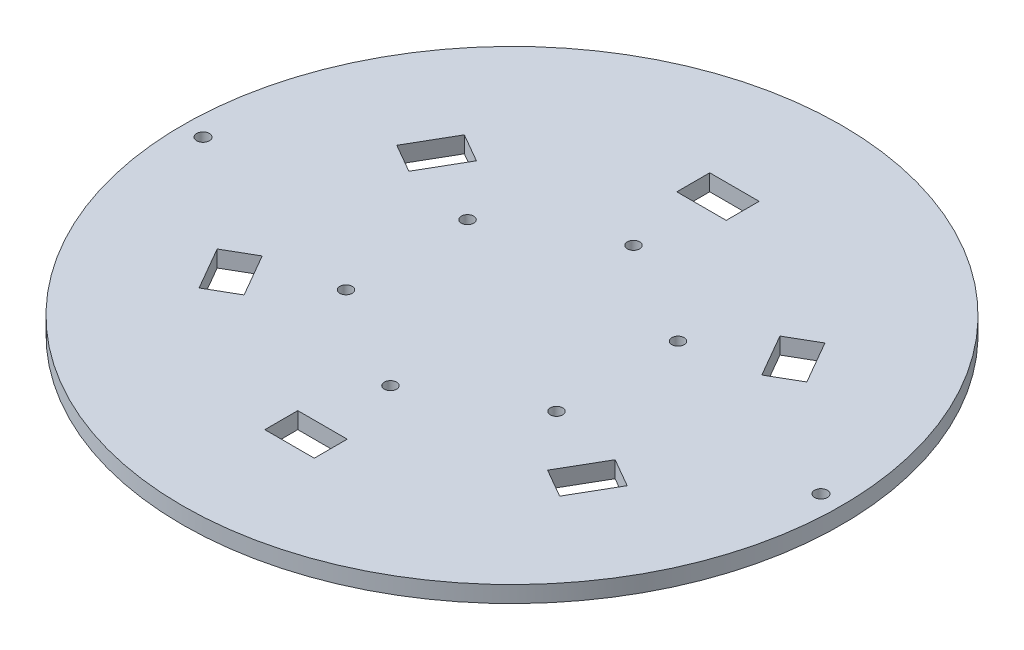
from build123d import *

# Parameters (mm, degrees)
BOSS_EXTRUDE1_DEPTH = 2
SKETCH2_R           = 1.55
CUT_EXTRUDE1_DEPTH  = 5
SKETCH3_W           = 12
SKETCH3_H           = 8
CUT_EXTRUDE2_DEPTH  = 5
SKETCH4_R           = 1.5
CUT_EXTRUDE4_DEPTH  = 10


with BuildPart() as part:
    # Sketch1 → Boss-Extrude1 (new body, symmetric)
    with BuildSketch(Plane(origin=(0, 0, 0), x_dir=(1, 0, 0), z_dir=(0, 1, 0))):
        with BuildLine():
            ThreePointArc((-6, 79.774682701), (0, -80), (6, 79.774682701))
            ThreePointArc((6, 79.774682701), (0, 80), (-6, 79.774682701))
        make_face()
    extrude(amount=BOSS_EXTRUDE1_DEPTH, both=True)

    # Sketch2 → Cut-Extrude1 (cut, through all)
    with BuildSketch(Plane.XZ.offset(2)):
        with Locations((75, 0)):
            Circle(SKETCH2_R)
        with Locations((-75, 0)):
            Circle(SKETCH2_R)
    extrude(amount=-CUT_EXTRUDE1_DEPTH, mode=Mode.SUBTRACT)

    # Sketch3 → Cut-Extrude2 (cut, through all)
    with BuildSketch(Plane(origin=(0, 2, 0), x_dir=(1, 0, 0), z_dir=(0, 1, 0))):
        Polygon((43.765371804, 32.196152423), (49.765371804, 21.803847577), (42.837168574, 17.803847577), (36.837168574, 28.196152423), align=None)
        with Locations((0, 50)):
            Rectangle(SKETCH3_W, SKETCH3_H)
        Polygon((49.765371804, -21.803847577), (43.765371804, -32.196152423), (36.837168574, -28.196152423), (42.837168574, -17.803847577), align=None)
        with Locations((0, -50)):
            Rectangle(SKETCH3_W, SKETCH3_H)
        Polygon((-43.765371804, -32.196152423), (-49.765371804, -21.803847577), (-42.837168574, -17.803847577), (-36.837168574, -28.196152423), align=None)
        Polygon((-49.765371804, 21.803847577), (-43.765371804, 32.196152423), (-36.837168574, 28.196152423), (-42.837168574, 17.803847577), align=None)
    extrude(amount=-CUT_EXTRUDE2_DEPTH, mode=Mode.SUBTRACT)

    # Sketch4 → Cut-Extrude4 (cut)
    with BuildSketch(Plane(origin=(0, 2, 0), x_dir=(1, 0, 0), z_dir=(0, 1, 0))):
        with Locations((0, -29.5)):
            Circle(SKETCH4_R)
        with Locations((-25.547749412, 14.75)):
            Circle(SKETCH4_R)
        with Locations((-25.547749412, -14.75)):
            Circle(SKETCH4_R)
        with Locations((25.547749412, -14.75)):
            Circle(SKETCH4_R)
        with Locations((25.547749412, 14.75)):
            Circle(SKETCH4_R)
        with Locations((0, 29.5)):
            Circle(SKETCH4_R)
    extrude(amount=-CUT_EXTRUDE4_DEPTH, mode=Mode.SUBTRACT)


solid = part.part
